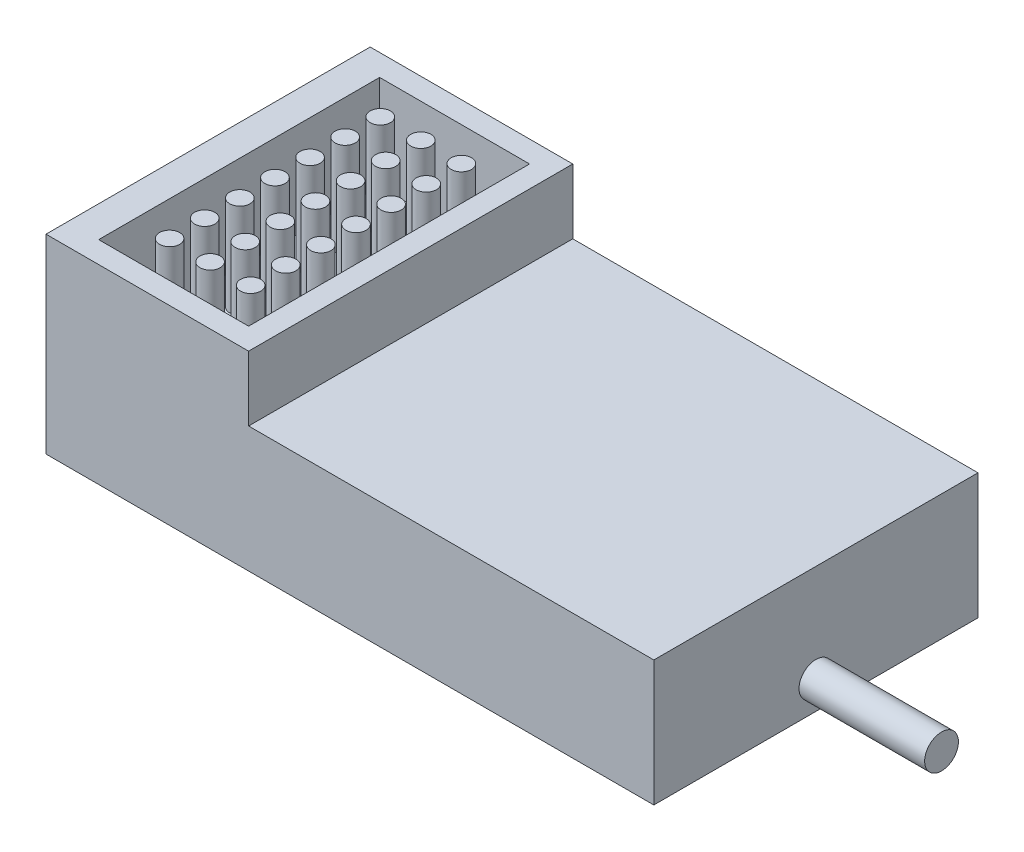
from build123d import *

# Parameters (mm, degrees)
SKETCH1_W           = 45
SKETCH1_H           = 24
BOSS_EXTRUDE1_DEPTH = 9.3
SKETCH2_R           = 1.25
BOSS_EXTRUDE2_DEPTH = 9.3
SKETCH3_W           = 15
SKETCH3_H           = 24
BOSS_EXTRUDE3_DEPTH = 4.8
SKETCH4_W           = 11.1
SKETCH4_H           = 20.8
SKETCH4_R           = 0.75
CUT_EXTRUDE1_DEPTH  = 7


with BuildPart() as part:
    # Sketch1 → Boss-Extrude1 (new body)
    with BuildSketch(Plane(origin=(0, 0, 0), x_dir=(1, 0, 0), z_dir=(0, 1, 0))):
        with Locations((22.5, 12)):
            Rectangle(SKETCH1_W, SKETCH1_H)
    extrude(amount=BOSS_EXTRUDE1_DEPTH)

    # Sketch2 → Boss-Extrude2 (add)
    with BuildSketch(Plane(origin=(45, 0, 0), x_dir=(0, 0, -1), z_dir=(1, 0, 0))):
        with Locations((12, 2.083449871)):
            Circle(SKETCH2_R)
    extrude(amount=BOSS_EXTRUDE2_DEPTH)

    # Sketch3 → Boss-Extrude3 (add)
    with BuildSketch(Plane(origin=(0, 9.3, 0), x_dir=(1, 0, 0), z_dir=(0, 1, 0))):
        with Locations((7.5, 12)):
            Rectangle(SKETCH3_W, SKETCH3_H)
    extrude(amount=BOSS_EXTRUDE3_DEPTH)

    # Sketch4 → Cut-Extrude1 (cut)
    with BuildSketch(Plane(origin=(0, 14.1, 0), x_dir=(1, 0, 0), z_dir=(0, 1, 0))):
        with Locations((7.85, 12)):
            Rectangle(SKETCH4_W, SKETCH4_H)
        with Locations((4.85, 19.9)):
            Circle(SKETCH4_R, mode=Mode.SUBTRACT)
        with Locations((7.85, 19.9)):
            Circle(SKETCH4_R, mode=Mode.SUBTRACT)
        with Locations((10.85, 19.9)):
            Circle(SKETCH4_R, mode=Mode.SUBTRACT)
        with Locations((4.85, 17.3)):
            Circle(SKETCH4_R, mode=Mode.SUBTRACT)
        with Locations((7.85, 17.3)):
            Circle(SKETCH4_R, mode=Mode.SUBTRACT)
        with Locations((10.85, 17.3)):
            Circle(SKETCH4_R, mode=Mode.SUBTRACT)
        with Locations((4.85, 14.7)):
            Circle(SKETCH4_R, mode=Mode.SUBTRACT)
        with Locations((7.85, 14.7)):
            Circle(SKETCH4_R, mode=Mode.SUBTRACT)
        with Locations((10.85, 14.7)):
            Circle(SKETCH4_R, mode=Mode.SUBTRACT)
        with Locations((4.85, 12.1)):
            Circle(SKETCH4_R, mode=Mode.SUBTRACT)
        with Locations((7.85, 12.1)):
            Circle(SKETCH4_R, mode=Mode.SUBTRACT)
        with Locations((10.85, 12.1)):
            Circle(SKETCH4_R, mode=Mode.SUBTRACT)
        with Locations((4.85, 9.5)):
            Circle(SKETCH4_R, mode=Mode.SUBTRACT)
        with Locations((7.85, 9.5)):
            Circle(SKETCH4_R, mode=Mode.SUBTRACT)
        with Locations((10.85, 9.5)):
            Circle(SKETCH4_R, mode=Mode.SUBTRACT)
        with Locations((4.85, 6.9)):
            Circle(SKETCH4_R, mode=Mode.SUBTRACT)
        with Locations((7.85, 6.9)):
            Circle(SKETCH4_R, mode=Mode.SUBTRACT)
        with Locations((10.85, 6.9)):
            Circle(SKETCH4_R, mode=Mode.SUBTRACT)
        with Locations((4.85, 4.3)):
            Circle(SKETCH4_R, mode=Mode.SUBTRACT)
        with Locations((7.85, 4.3)):
            Circle(SKETCH4_R, mode=Mode.SUBTRACT)
        with Locations((10.85, 4.3)):
            Circle(SKETCH4_R, mode=Mode.SUBTRACT)
    extrude(amount=-CUT_EXTRUDE1_DEPTH, mode=Mode.SUBTRACT)


solid = part.part
